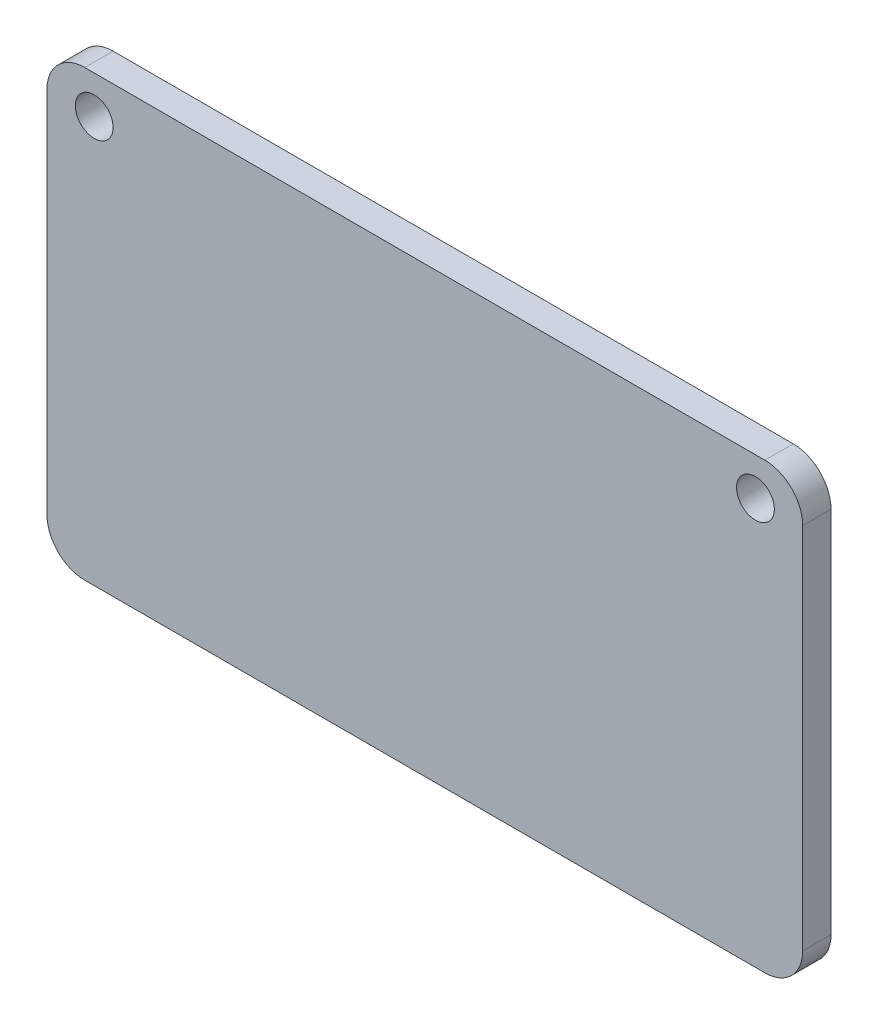
from build123d import *

# Parameters (mm, degrees)
ESQUISSE1_W        = 80
ESQUISSE1_H        = 47
ESQUISSE1_R        = 2
BOSS_EXTRU_1_DEPTH = 3
CONG_1_R           = 4


with BuildPart() as part:
    # Esquisse1 → Boss.-Extru.1 (new body)
    with BuildSketch(Plane.XY):
        with Locations((40, -23.5)):
            Rectangle(ESQUISSE1_W, ESQUISSE1_H)
        with Locations((5, -4)):
            Circle(ESQUISSE1_R, mode=Mode.SUBTRACT)
        with Locations((75, -4)):
            Circle(ESQUISSE1_R, mode=Mode.SUBTRACT)
    extrude(amount=BOSS_EXTRU_1_DEPTH)

    # Congé1
    cong_1_edges = [part.edges().sort_by_distance(p)[0] for p in [
        (0, 0, 1.5),
        (80, 0, 1.5),
        (80, -47, 1.5),
        (0, -47, 1.5),
    ]]
    fillet(cong_1_edges, radius=CONG_1_R)


solid = part.part
